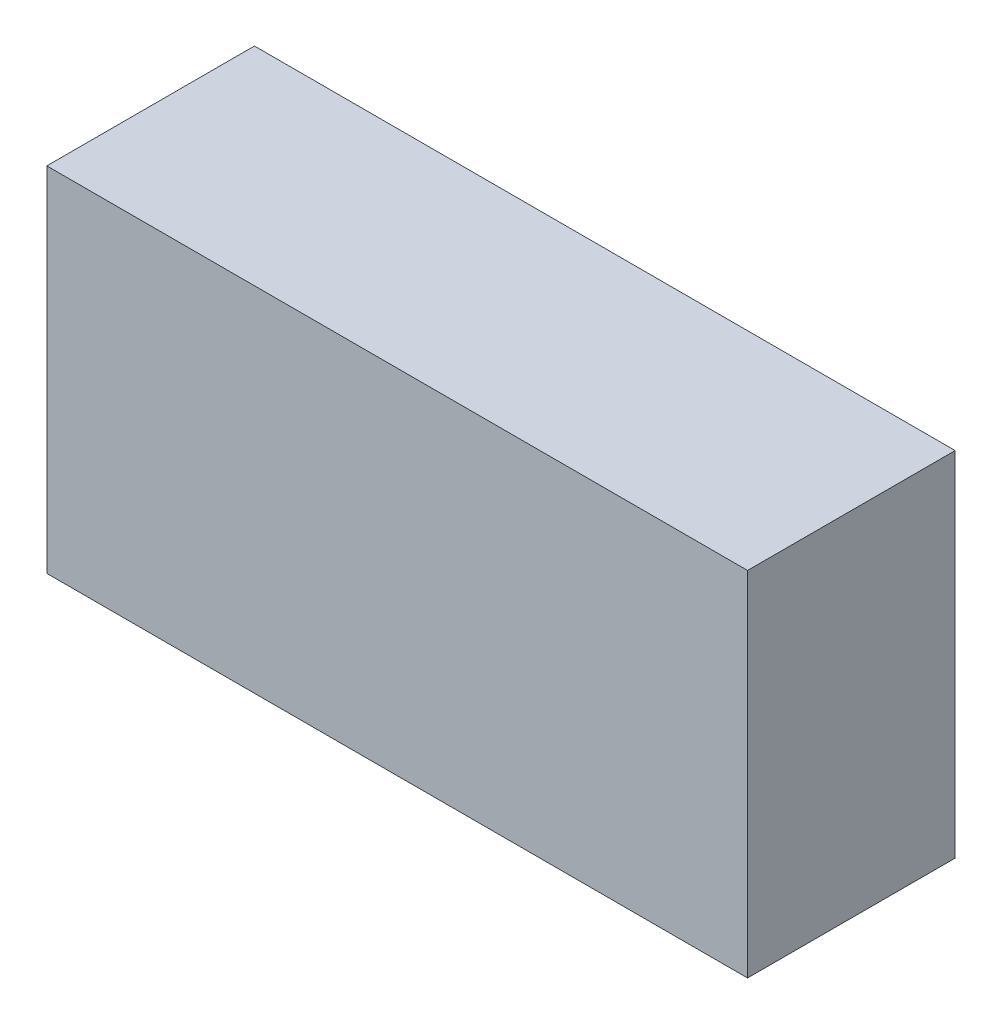
from build123d import *

# Parameters (mm, degrees)
SKETCH_1_W          = 135
SKETCH_1_H          = 40
EXTRUDE_310_DEPTH   = 68
SKETCH_2_W          = 39
SKETCH_2_H          = 15
CUT_EXTRUDE_1_DEPTH = 66
SKETCH_4_W          = 53
SKETCH_4_H          = 9.428155193
CUT_EXTRUDE_2_DEPTH = 66
SKETCH_6_W          = 53
SKETCH_6_H          = 10.153175229
CUT_EXTRUDE_3_DEPTH = 66
SKETCH_7_W          = 30.334064535
SKETCH_7_H          = 3
SKETCH_7_W_2        = 33.750062794
SKETCH_7_W_3        = 31.017264187
CUT_EXTRUDE_4_DEPTH = 66


with BuildPart() as part:
    # Эскиз1 → Extrude 310 (new body)
    with BuildSketch(Plane(origin=(0, 0, 0), x_dir=(1, 0, 0), z_dir=(0, 1, 0))):
        with Locations((67.5, 20)):
            Rectangle(SKETCH_1_W, SKETCH_1_H)
    extrude(amount=EXTRUDE_310_DEPTH)

    # Эскиз2 → Вырез-Вытянуть1 (cut)
    with BuildSketch(Plane.XZ):
        with Locations((21.5, -10.5)):
            Rectangle(SKETCH_2_W, SKETCH_2_H)
        with Locations((67.5, -10.5)):
            Rectangle(SKETCH_2_W, SKETCH_2_H)
        with Locations((113.5, -10.5)):
            Rectangle(SKETCH_2_W, SKETCH_2_H)
        with Locations((67.5, -28.5)):
            Rectangle(SKETCH_2_W, SKETCH_2_H)
        with Locations((113.5, -28.5)):
            Rectangle(SKETCH_2_W, SKETCH_2_H)
        with Locations((21.5, -28.5)):
            Rectangle(SKETCH_2_W, SKETCH_2_H)
    extrude(amount=-CUT_EXTRUDE_1_DEPTH, mode=Mode.SUBTRACT)

    # Эскиз4 → Вырез-Вытянуть2 (cut)
    with BuildSketch(Plane.XZ):
        with Locations((67.5, -10.503524842)):
            Rectangle(SKETCH_4_W, SKETCH_4_H)
    extrude(amount=-CUT_EXTRUDE_2_DEPTH, mode=Mode.SUBTRACT)

    # Эскиз6 → Вырез-Вытянуть3 (cut)
    with BuildSketch(Plane.XZ):
        with Locations((67.5, -28.288326327)):
            Rectangle(SKETCH_6_W, SKETCH_6_H)
    extrude(amount=-CUT_EXTRUDE_3_DEPTH, mode=Mode.SUBTRACT)

    # Эскиз7 → Вырез-Вытянуть4 (cut)
    with BuildSketch(Plane.XZ):
        with Locations((22.818742778, -19.5)):
            Rectangle(SKETCH_7_W, SKETCH_7_H)
        with Locations((67.158400174, -19.5)):
            Rectangle(SKETCH_7_W_2, SKETCH_7_H)
        with Locations((112.112937257, -19.5)):
            Rectangle(SKETCH_7_W_3, SKETCH_7_H)
    extrude(amount=-CUT_EXTRUDE_4_DEPTH, mode=Mode.SUBTRACT)


solid = part.part
